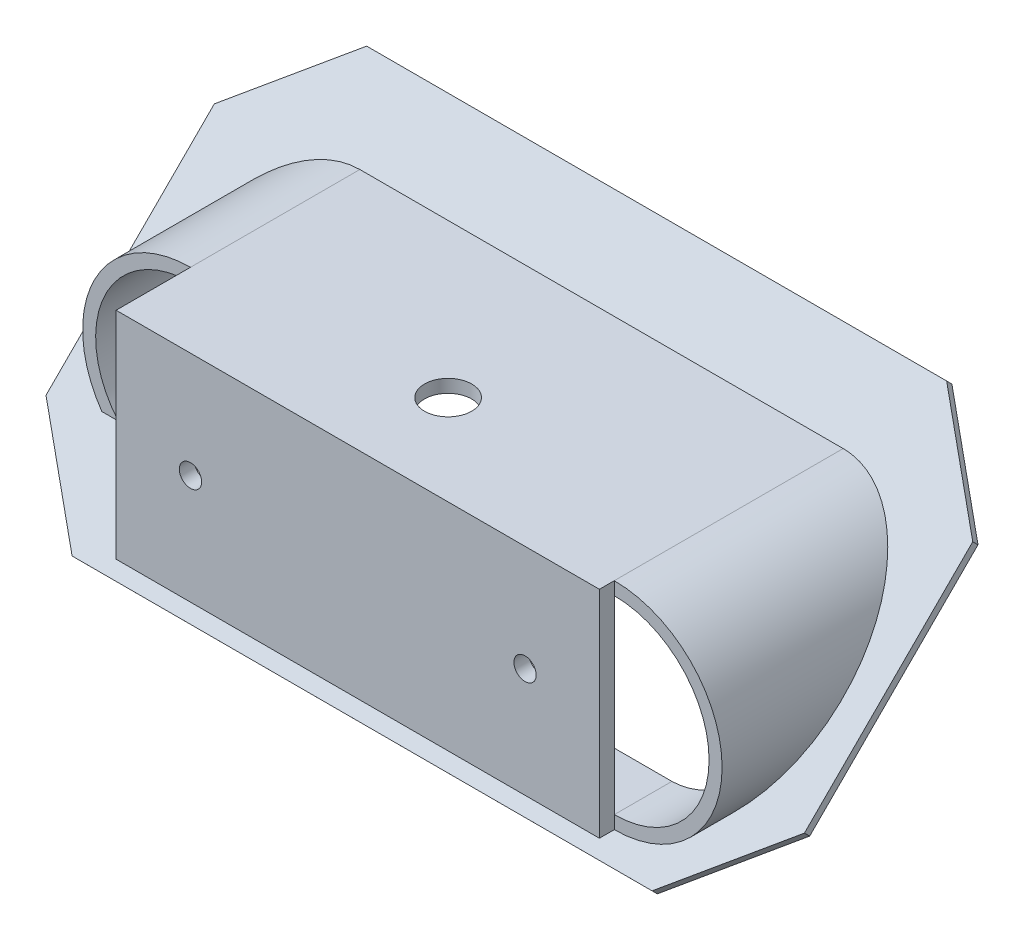
from build123d import *

# Parameters (mm, degrees)
BOSS_EXTRUDE12_DEPTH            = 80
CUT_EXTRUDE10_DEPTH             = 80.5
CUT_EXTRUDE10_DEPTH_BACK        = 15.5
SKETCH37_W                      = 102
SKETCH37_H                      = 56
BOSS_EXTRUDE16_DEPTH            = 3
CUT_EXTRUDE11_DEPTH             = 86.294722428
SKETCH40_W                      = 127.486838651
SKETCH40_H                      = 54.833163407
CUT_EXTRUDE12_DEPTH             = 35.662124955
CUT_EXTRUDE12_DEPTH_BACK        = 1.75
CUT_EXTRUDE14_DEPTH             = 18.5
F_1_4_0_25_DIAMETER_HOLE1_D     = 6.35
F_1_4_0_25_DIAMETER_HOLE1_DEPTH = 5
F_1_4_0_25_DIAMETER_HOLE1_TIP   = 1.907732465
CHAMFER2_SIZE                   = 12
CHAMFER3_SIZE                   = 2
BOSS_EXTRUDE17_START            = -29
SKETCH50_W                      = 65
SKETCH50_H                      = 2
BOSS_EXTRUDE17_DEPTH            = 29
F_3_0MM_DOWEL_HOLE1_D           = 3
F_3_0MM_DOWEL_HOLE1_DEPTH       = 2


with BuildPart() as part:
    # Sketch22 → Boss-Extrude12 (new body)
    with BuildSketch(Plane.XY):
        with BuildLine():
            Line((32.5, -14.5), (-32.5, -14.5))
            ThreePointArc((-32.5, -14.5), (-47, 0), (-32.5, 14.5))
            Line((-32.5, 14.5), (32.5, 14.5))
            ThreePointArc((32.5, 14.5), (47, 0), (32.5, -14.5))
        make_face()
    extrude(amount=BOSS_EXTRUDE12_DEPTH)

    # Sketch35 → Cut-Extrude10 (cut, two sides)
    with BuildSketch(Plane(origin=(-32.5, 0, 0), x_dir=(0, 0, -1), z_dir=(1, 0, 0))) as cut_extrude10_sk:
        Polygon((0, 14.5), (-29.026860374, -14.5), (0, -14.5), align=None)
    extrude(amount=CUT_EXTRUDE10_DEPTH, mode=Mode.SUBTRACT)
    extrude(cut_extrude10_sk.sketch, amount=-CUT_EXTRUDE10_DEPTH_BACK, mode=Mode.SUBTRACT)

    # Sketch37 → Boss-Extrude16 (add)
    with BuildSketch(Plane(origin=(0, 7.256711984, 7.249996893), x_dir=(-1, 0, 0), z_dir=(0, -0.707434022, -0.706779389))):
        with Locations((0, -10.26729429)):
            Rectangle(SKETCH37_W, SKETCH37_H)
    extrude(amount=-BOSS_EXTRUDE16_DEPTH)

    # Sketch38 → Cut-Extrude11 (cut, through all)
    with BuildSketch(Plane.XY.offset(80)):
        with BuildLine():
            Line((-32.5, 12.75), (32.5, 12.75))
            ThreePointArc((32.5, 12.75), (45.25, 0), (32.5, -12.75))
            Line((32.5, -12.75), (-32.5, -12.75))
            ThreePointArc((-32.5, -12.75), (-45.25, 0), (-32.5, 12.75))
        make_face()
    extrude(amount=-CUT_EXTRUDE11_DEPTH, mode=Mode.SUBTRACT)

    # Sketch40 → Cut-Extrude12 (cut, two sides)
    with BuildSketch(Plane(origin=(0, -12.75, 0), x_dir=(1, 0, 0), z_dir=(0, 1, 0))) as cut_extrude12_sk:
        with Locations((5.984726224, -62.441589639)):
            Rectangle(SKETCH40_W, SKETCH40_H)
    extrude(amount=CUT_EXTRUDE12_DEPTH, mode=Mode.SUBTRACT)
    extrude(cut_extrude12_sk.sketch, amount=-CUT_EXTRUDE12_DEPTH_BACK, mode=Mode.SUBTRACT)

    # Sketch42 → Cut-Extrude14 (cut)
    with BuildSketch(Plane.ZY.offset(51)):
        Polygon((35.025007935, 14.5), (27.025007935, 14.5), (27.025007935, -8.259321849), (33.271466325, -14.5), (35.025007935, -14.5), align=None)
    extrude(amount=-CUT_EXTRUDE14_DEPTH, mode=Mode.SUBTRACT)

    # 1/4 (0.25) Diameter Hole1
    with Locations(Plane(origin=(0, 14.5, 0), x_dir=(1, 0, 0), z_dir=(0, 1, 0))):
        with Locations((2.6293e-05, -24.875007935)):
            Hole(F_1_4_0_25_DIAMETER_HOLE1_D / 2, depth=F_1_4_0_25_DIAMETER_HOLE1_DEPTH)
            with Locations((0, 0, -(F_1_4_0_25_DIAMETER_HOLE1_DEPTH + F_1_4_0_25_DIAMETER_HOLE1_TIP / 2))):  # 118° drill point
                Cone(0, F_1_4_0_25_DIAMETER_HOLE1_D / 2, F_1_4_0_25_DIAMETER_HOLE1_TIP, mode=Mode.SUBTRACT)

    # Chamfer2
    chamfer2_edges = [part.edges().sort_by_distance(p)[0] for p in [
        (51, -18.728671856, 35.381751886),
        (51, 20.850973922, -4.234553344),
        (-51, 20.850973922, -4.234553344),
        (-51, -18.728671856, 35.381751886),
    ]]
    chamfer(chamfer2_edges, length=CHAMFER2_SIZE)

    # Chamfer3
    chamfer3_edges = [part.edges().sort_by_distance(p)[0] for p in [
        (-51, 0, 14.513430187),
        (51, 0, 14.513430187),
        (0, -19.789822889, 34.321582802),
        (0, 19.789822889, -5.294722428),
        (-45, -15.549146556, 30.07697867),
        (45, -15.549146556, 30.07697867),
        (45, 15.549146556, -1.050118296),
        (-45, 15.549146556, -1.050118296),
    ]]
    chamfer(chamfer3_edges, length=CHAMFER3_SIZE)

    # Sketch50 → Boss-Extrude17 (add)
    with BuildSketch(Plane(origin=(0, 14.5, 0), x_dir=(1, 0, 0), z_dir=(0, 1, 0)).offset(BOSS_EXTRUDE17_START)):
        with Locations((0, -36.025007935)):
            Rectangle(SKETCH50_W, SKETCH50_H)
    extrude(amount=BOSS_EXTRUDE17_DEPTH)

    # Ø3.0mm Dowel Hole1
    with Locations(Plane(origin=(0, 0, 35.025007935), x_dir=(-1, 0, 0), z_dir=(0, 0, -1))):
        with Locations((-22.500026293, 0.25), (22.499973707, 0.25)):
            Hole(F_3_0MM_DOWEL_HOLE1_D / 2, depth=F_3_0MM_DOWEL_HOLE1_DEPTH)


solid = part.part
